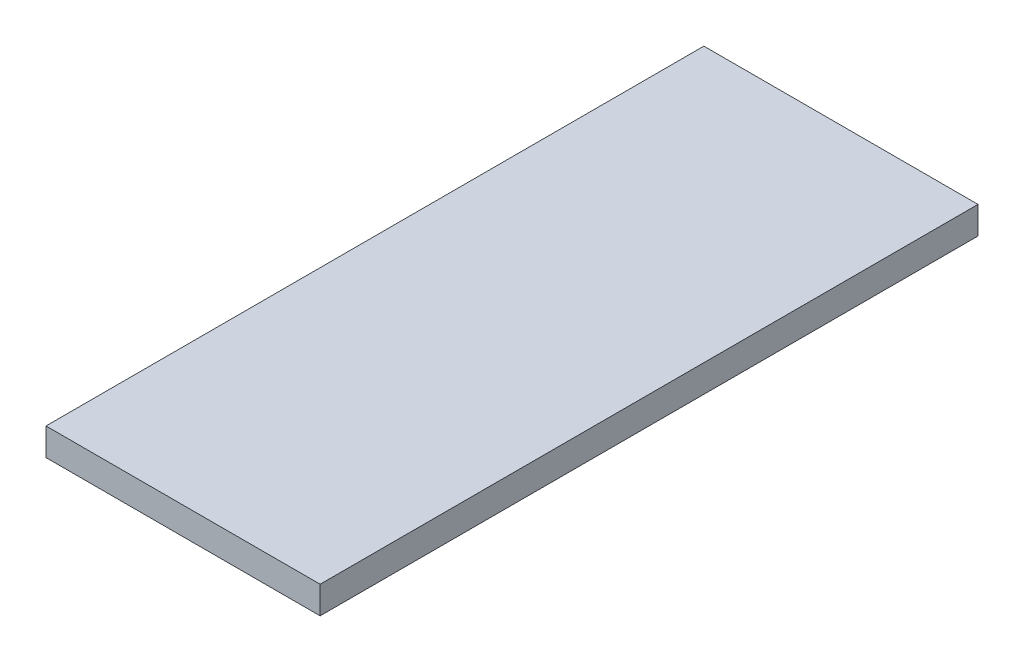
from build123d import *

# Parameters (mm, degrees)
SKETCH_1_W      = 50
SKETCH_1_H      = 120
EXTRUDE_1_DEPTH = 5


with BuildPart() as part:
    # Эскиз1 → Бобышка-Вытянуть1 (new body)
    with BuildSketch(Plane(origin=(0, 0, 0), x_dir=(1, 0, 0), z_dir=(0, 1, 0))):
        with Locations((25, 60)):
            Rectangle(SKETCH_1_W, SKETCH_1_H)
    extrude(amount=EXTRUDE_1_DEPTH)


solid = part.part
